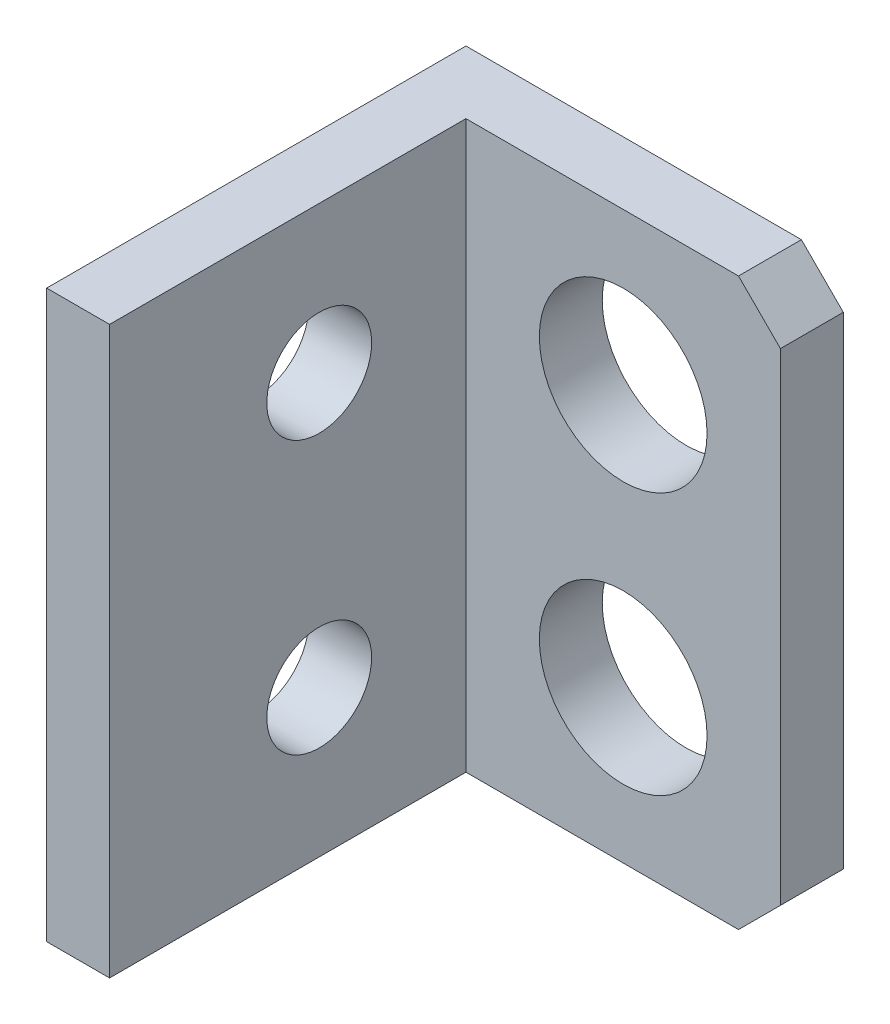
from build123d import *

# Parameters (mm, degrees)
SKETCH1_W           = 20
SKETCH1_H           = 27
SKETCH1_R           = 2.5
BOSS_EXTRUDE1_DEPTH = 3
SKETCH2_W           = 3
SKETCH2_H           = 27
BOSS_EXTRUDE2_DEPTH = 15
SKETCH3_R           = 4
CUT_EXTRUDE1_DEPTH  = 15
CHAMFER1_SIZE       = 2


with BuildPart() as part:
    # Sketch1 → Boss-Extrude1 (new body)
    with BuildSketch(Plane(origin=(0, 0, 0), x_dir=(0, 0, -1), z_dir=(1, 0, 0))):
        with Locations((10, 13.5)):
            Rectangle(SKETCH1_W, SKETCH1_H)
        with Locations((10, 7)):
            Circle(SKETCH1_R, mode=Mode.SUBTRACT)
        with Locations((10, 20)):
            Circle(SKETCH1_R, mode=Mode.SUBTRACT)
    extrude(amount=BOSS_EXTRUDE1_DEPTH)

    # Sketch2 → Boss-Extrude2 (add)
    with BuildSketch(Plane(origin=(3, 0, 0), x_dir=(0, 0, -1), z_dir=(1, 0, 0))):
        with Locations((18.5, 13.5)):
            Rectangle(SKETCH2_W, SKETCH2_H)
    extrude(amount=BOSS_EXTRUDE2_DEPTH)

    # Sketch3 → Cut-Extrude1 (cut)
    with BuildSketch(Plane(origin=(0, 0, -20), x_dir=(-1, 0, 0), z_dir=(0, 0, -1))):
        with Locations((-10.5, 19.75)):
            Circle(SKETCH3_R)
        with Locations((-10.5, 7.25)):
            Circle(SKETCH3_R)
    extrude(amount=-CUT_EXTRUDE1_DEPTH, mode=Mode.SUBTRACT)

    # Chamfer1
    chamfer1_edges = [part.edges().sort_by_distance(p)[0] for p in [
        (18, 27, -18.5),
        (18, 0, -18.5),
    ]]
    chamfer(chamfer1_edges, length=CHAMFER1_SIZE)


solid = part.part
